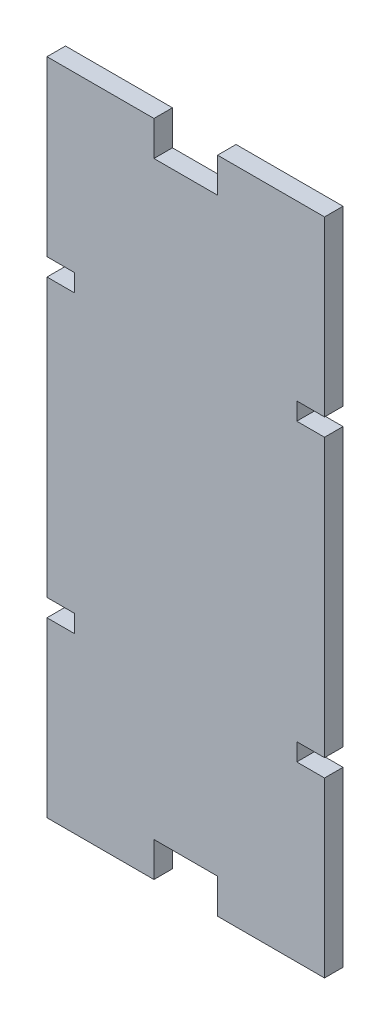
from build123d import *

# Parameters (mm, degrees)
SKETCH1_W           = 76.2
SKETCH1_H           = 180.975
BOSS_EXTRUDE1_DEPTH = 5.08
SKETCH3_W           = 17.4625
SKETCH3_H           = 9.525
CUT_EXTRUDE1_DEPTH  = 6.08
SKETCH4_W           = 7.62
SKETCH4_H           = 4.826
CUT_EXTRUDE2_DEPTH  = 6.08


with BuildPart() as part:
    # Sketch1 → Boss-Extrude1 (new body)
    with BuildSketch(Plane.XY):
        Rectangle(SKETCH1_W, SKETCH1_H)
    extrude(amount=BOSS_EXTRUDE1_DEPTH)

    # Sketch3 → Cut-Extrude1 (cut, through all)
    with BuildSketch(Plane.XY.offset(5.08)):
        with Locations((0, -85.725)):
            Rectangle(SKETCH3_W, SKETCH3_H)
        with Locations((0, 85.725)):
            Rectangle(SKETCH3_W, SKETCH3_H)
    extrude(amount=-CUT_EXTRUDE1_DEPTH, mode=Mode.SUBTRACT)

    # Sketch4 → Cut-Extrude2 (cut, through all)
    with BuildSketch(Plane.XY.offset(5.08)):
        with Locations((-34.29, 40.513)):
            Rectangle(SKETCH4_W, SKETCH4_H)
        with Locations((34.29, 40.513)):
            Rectangle(SKETCH4_W, SKETCH4_H)
        with Locations((34.29, -40.513)):
            Rectangle(SKETCH4_W, SKETCH4_H)
        with Locations((-34.29, -40.513)):
            Rectangle(SKETCH4_W, SKETCH4_H)
    extrude(amount=-CUT_EXTRUDE2_DEPTH, mode=Mode.SUBTRACT)


solid = part.part
